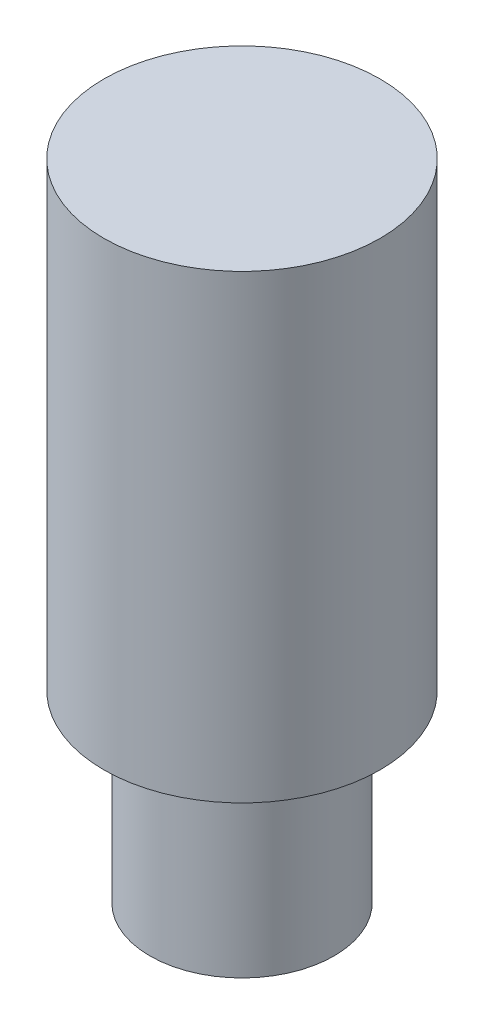
from build123d import *

# Parameters (mm, degrees)
SKIZZE1_R                       = 1
AUFSATZ_LINEAR_AUSTRAGEN1_DEPTH = 2
SKIZZE2_R                       = 1.5
AUFSATZ_LINEAR_AUSTRAGEN2_DEPTH = 5


with BuildPart() as part:
    # Skizze1 → Aufsatz-Linear austragen1 (new body)
    with BuildSketch(Plane(origin=(0, 0, 0), x_dir=(1, 0, 0), z_dir=(0, 1, 0))):
        Circle(SKIZZE1_R)
    extrude(amount=AUFSATZ_LINEAR_AUSTRAGEN1_DEPTH)

    # Skizze2 → Aufsatz-Linear austragen2 (add)
    with BuildSketch(Plane(origin=(0, 2, 0), x_dir=(1, 0, 0), z_dir=(0, 1, 0))):
        Circle(SKIZZE2_R)
    extrude(amount=AUFSATZ_LINEAR_AUSTRAGEN2_DEPTH)


solid = part.part
